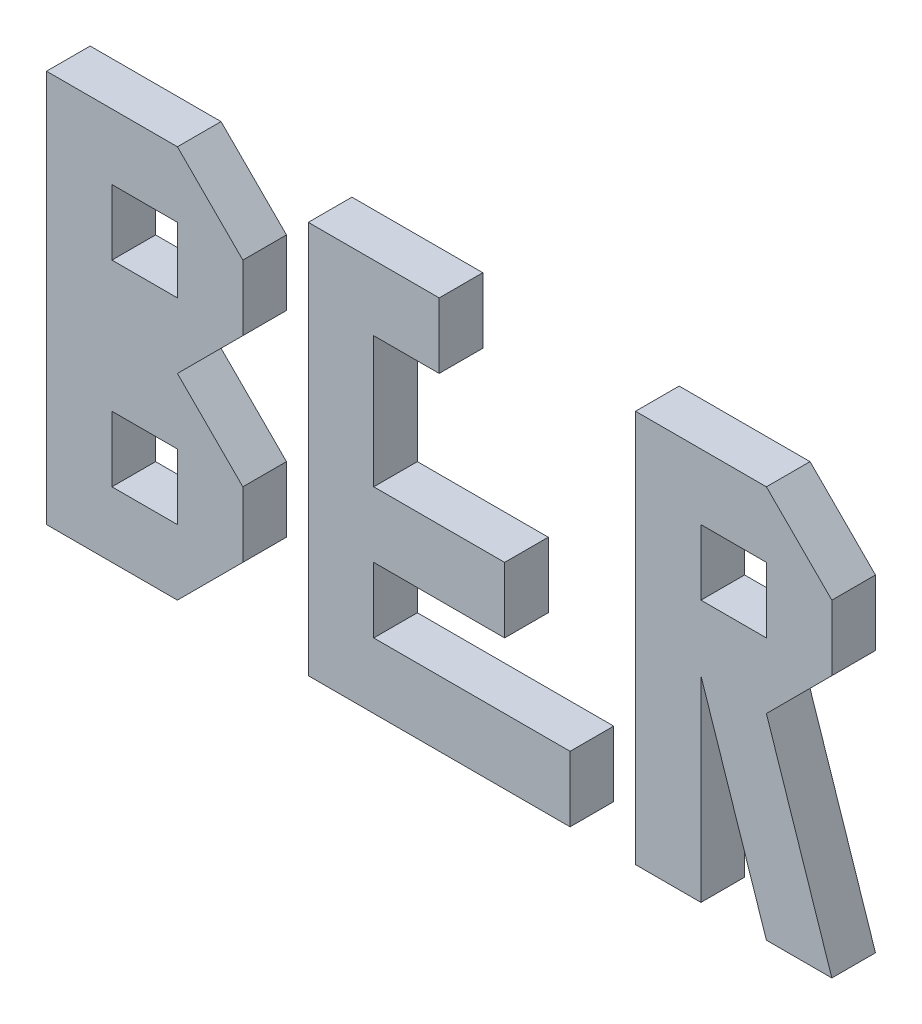
from build123d import *

# Parameters (mm, degrees)
SKETCH2_W        = 15
SKETCH2_H        = 15
EXTRUDE1_DEPTH   = 10
EXTRUDE1_2_DEPTH = 10
EXTRUDE1_3_DEPTH = 10


with BuildPart() as part:
    # Sketch2 → Extrude1 (new body)
    with BuildSketch(Plane.XY):
        Polygon((30, 0), (0, 0), (0, 90), (30, 90), (45, 75), (45, 60), (30, 45), (45, 30), (45, 15), align=None)
        with Locations((22.5, 67.5)):
            Rectangle(SKETCH2_W, SKETCH2_H, mode=Mode.SUBTRACT)
        with Locations((22.5, 22.5)):
            Rectangle(SKETCH2_W, SKETCH2_H, mode=Mode.SUBTRACT)
    extrude(amount=EXTRUDE1_DEPTH)


with BuildPart() as body_2:
    # Sketch2 → Extrude1 2 (new body)
    with BuildSketch(Plane.XY):
        Polygon((60, 0), (120, 0), (120, 15), (75, 15), (75, 30), (105, 30), (105, 45), (75, 45), (75, 75), (90, 75), (90, 90), (60, 90), align=None)
    extrude(amount=EXTRUDE1_2_DEPTH)


with BuildPart() as body_3:
    # Sketch2 → Extrude1 3 (new body)
    with BuildSketch(Plane.XY):
        Polygon((150, 45), (150, 0), (135, 0), (135, 90), (165, 90), (180, 75), (180, 60), (165, 45), (180, 0), (165, 0), align=None)
        with Locations((157.5, 67.5)):
            Rectangle(SKETCH2_W, SKETCH2_H, mode=Mode.SUBTRACT)
    extrude(amount=EXTRUDE1_3_DEPTH)


solid = Compound([part.part, body_2.part, body_3.part])
